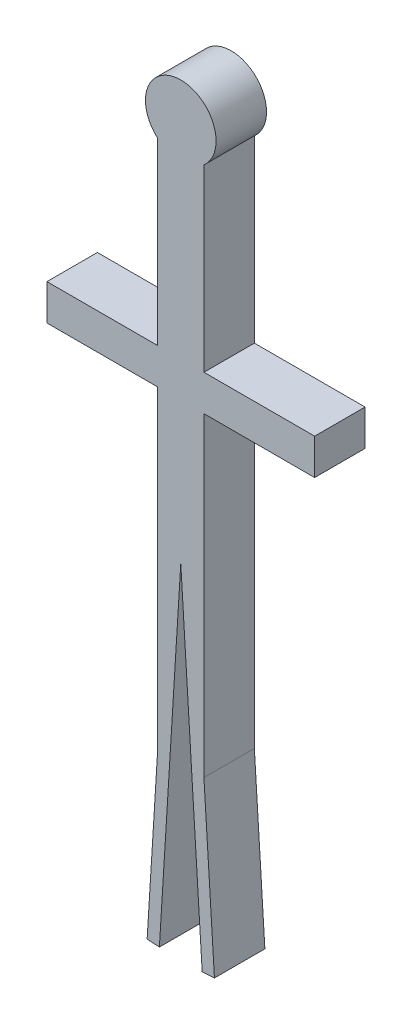
from build123d import *

# Parameters (mm, degrees)
BOSS_EXTRUDE2_DEPTH = 127


with BuildPart() as part:
    # Sketch1 → Boss-Extrude2 (new body)
    with BuildSketch(Plane.XY):
        with BuildLine():
            Line((-58.272673139, -67.137959198), (-58.272673139, -519.346809046))
            Line((-58.272673139, -519.346809046), (-336.974932069, -519.346809046))
            Line((-336.974932069, -519.346809046), (-336.974932069, -609.62196559))
            Line((-336.974932069, -609.62196559), (-58.272673139, -609.62196559))
            Line((-58.272673139, -609.62196559), (-58.272673139, -1403.11866405))
            Line((-58.272673139, -1403.11866405), (-84.73010294, -1826.874477175))
            Line((-84.73010294, -1826.874477175), (-53.889938316, -1828.8))
            Line((-53.889938316, -1828.8), (0, -965.671011219))
            Line((0, -965.671011219), (53.889938316, -1828.8))
            Line((53.889938316, -1828.8), (84.73010294, -1826.874477175))
            Line((84.73010294, -1826.874477175), (58.272673139, -1403.11866405))
            Line((58.272673139, -1403.11866405), (58.272673139, -609.62196559))
            Line((58.272673139, -609.62196559), (336.974932069, -609.62196559))
            Line((336.974932069, -609.62196559), (336.974932069, -519.346809046))
            Line((336.974932069, -519.346809046), (58.272673139, -519.346809046))
            Line((58.272673139, -519.346809046), (58.272673139, -67.137959198))
            ThreePointArc((58.272673139, -67.137959198), (0, 88.9), (-58.272673139, -67.137959198))
        make_face()
    extrude(amount=BOSS_EXTRUDE2_DEPTH)


solid = part.part
